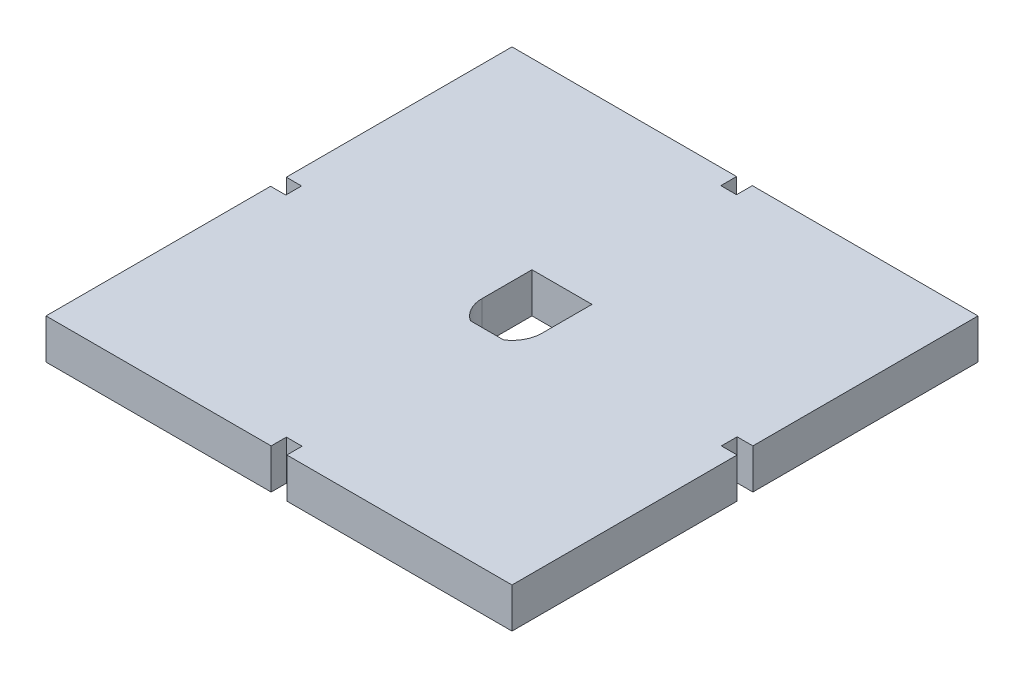
from build123d import *

# Parameters (mm, degrees)
SKETCH1_W           = 148
SKETCH1_H           = 148
BOSS_EXTRUDE1_DEPTH = 12.7
SKETCH2_W           = 10.53028371
SKETCH2_H           = 7.9375
CUT_EXTRUDE1_DEPTH  = 12.7
SKETCH4_W           = 10
SKETCH4_H           = 5
CUT_EXTRUDE2_DEPTH  = 210.688554766
CIRPATTERN1_COUNT   = 4


with BuildPart() as part:
    # Sketch1 → Boss-Extrude1 (new body)
    with BuildSketch(Plane(origin=(0, 0, 0), x_dir=(1, 0, 0), z_dir=(0, 1, 0))):
        with Locations((74, 74)):
            Rectangle(SKETCH1_W, SKETCH1_H)
    extrude(amount=BOSS_EXTRUDE1_DEPTH)

    # Sketch2 → Cut-Extrude1 (cut)
    with BuildSketch(Plane(origin=(0, 12.7, 0), x_dir=(1, 0, 0), z_dir=(0, 1, 0))):
        with BuildLine():
            ThreePointArc((79.265141855, 81.9375), (82.392737967, 78.504173), (83.525, 74))
            Line((83.525, 74), (83.525, 89.875))
            Line((83.525, 89.875), (64.475, 89.875))
            Line((64.475, 89.875), (64.475, 74))
            ThreePointArc((64.475, 74), (65.607262033, 78.504173), (68.734858145, 81.9375))
            ThreePointArc((68.734858145, 81.9375), (74, 83.525), (79.265141855, 81.9375))
        make_face()
        with BuildLine():
            ThreePointArc((79.265141855, 66.0625), (82.392737967, 69.495827), (83.525, 74))
            Line((83.525, 74), (79.265141855, 74))
            Line((79.265141855, 74), (79.265141855, 66.0625))
        make_face()
        with BuildLine():
            Line((79.265141855, 74), (83.525, 74))
            ThreePointArc((83.525, 74), (82.392737967, 78.504173), (79.265141855, 81.9375))
            Line((79.265141855, 81.9375), (79.265141855, 74))
        make_face()
        with BuildLine():
            Line((68.734858145, 66.0625), (68.734858145, 74))
            Line((68.734858145, 74), (64.475, 74))
            ThreePointArc((64.475, 74), (65.607262033, 69.495827), (68.734858145, 66.0625))
        make_face()
        with BuildLine():
            Line((64.475, 74), (68.734858145, 74))
            Line((68.734858145, 74), (68.734858145, 81.9375))
            ThreePointArc((68.734858145, 81.9375), (65.607262033, 78.504173), (64.475, 74))
        make_face()
        with Locations((74, 77.96875)):
            Rectangle(SKETCH2_W, SKETCH2_H)
        with BuildLine():
            Line((68.734858145, 81.9375), (79.265141855, 81.9375))
            ThreePointArc((79.265141855, 81.9375), (74, 83.525), (68.734858145, 81.9375))
        make_face()
        with BuildLine():
            ThreePointArc((79.265141855, 66.0625), (82.392737967, 69.495827), (83.525, 74))
            Line((83.525, 74), (79.265141855, 74))
            Line((79.265141855, 74), (79.265141855, 66.0625))
        make_face()
        with BuildLine():
            Line((79.265141855, 74), (83.525, 74))
            ThreePointArc((83.525, 74), (82.392737967, 78.504173), (79.265141855, 81.9375))
            Line((79.265141855, 81.9375), (79.265141855, 74))
        make_face()
        with BuildLine():
            Line((68.734858145, 66.0625), (68.734858145, 74))
            Line((68.734858145, 74), (64.475, 74))
            ThreePointArc((64.475, 74), (65.607262033, 69.495827), (68.734858145, 66.0625))
        make_face()
        with BuildLine():
            Line((64.475, 74), (68.734858145, 74))
            Line((68.734858145, 74), (68.734858145, 81.9375))
            ThreePointArc((68.734858145, 81.9375), (65.607262033, 78.504173), (64.475, 74))
        make_face()
        with Locations((74, 70.03125)):
            Rectangle(SKETCH2_W, SKETCH2_H)
    extrude(amount=-CUT_EXTRUDE1_DEPTH, mode=Mode.SUBTRACT)

    # Sketch4 → Cut-Extrude2 (cut, through all)
    with BuildSketch(Plane(origin=(0, 12.7, 0), x_dir=(1, 0, 0), z_dir=(0, 1, 0))):
        with Locations((148, 74)):
            Rectangle(SKETCH4_W, SKETCH4_H)
    cut_extrude2 = extrude(amount=-CUT_EXTRUDE2_DEPTH, mode=Mode.SUBTRACT)

    # CirPattern1: Cut-Extrude2 ×4 about axis
    cirpattern1_axis = Axis((73.916648848, 12.7, -73.910393573), (0, 1, 0))
    for i in range(1, CIRPATTERN1_COUNT):
        add(cut_extrude2.rotate(cirpattern1_axis, i * 360 / CIRPATTERN1_COUNT), mode=Mode.SUBTRACT)


solid = part.part
